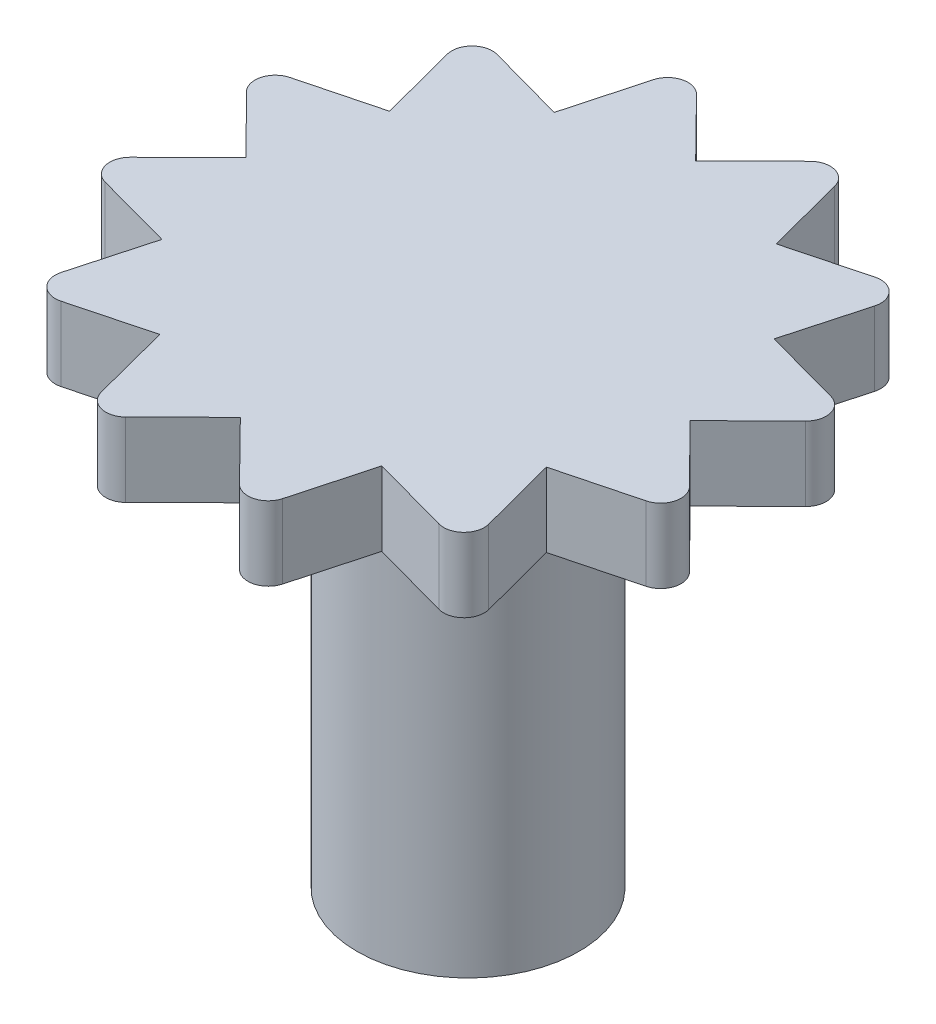
from build123d import *

# Parameters (mm, degrees)
BOSS_EXTRUDE1_DEPTH = 1
SKETCH2_R           = 1.5
BOSS_EXTRUDE2_DEPTH = 6


with BuildPart() as part:
    # Sketch1 → Boss-Extrude1 (new body)
    with BuildSketch(Plane(origin=(0, 0, 0), x_dir=(1, 0, 0), z_dir=(0, 1, 0))):
        with BuildLine():
            Line((0.038153439, 3.037815087), (0.816252158, 3.809013473))
            ThreePointArc((0.816252158, 3.809013473), (1.082123997, 3.875868882), (1.274025664, 3.680085251))
            Line((1.274025664, 3.680085251), (1.551949391, 2.611748318))
            Line((1.551949391, 2.611748318), (2.611401842, 2.890576352))
            ThreePointArc((2.611401842, 2.890576352), (2.875081312, 2.815538915), (2.943381216, 2.550034483))
            Line((2.943381216, 2.550034483), (2.649901757, 1.485865696))
            Line((2.649901757, 1.485865696), (3.70682851, 1.197611631))
            ThreePointArc((3.70682851, 1.197611631), (3.897662912, 1.00078757), (3.824060148, 0.736704035))
            Line((3.824060148, 0.736704035), (3.037815087, -0.038153439))
            Line((3.037815087, -0.038153439), (3.809013473, -0.816252158))
            ThreePointArc((3.809013473, -0.816252158), (3.875868882, -1.082123997), (3.680085251, -1.274025664))
            Line((3.680085251, -1.274025664), (2.611748318, -1.551949391))
            Line((2.611748318, -1.551949391), (2.890576352, -2.611401842))
            ThreePointArc((2.890576352, -2.611401842), (2.815538915, -2.875081312), (2.550034483, -2.943381216))
            Line((2.550034483, -2.943381216), (1.485865696, -2.649901757))
            Line((1.485865696, -2.649901757), (1.197611631, -3.70682851))
            ThreePointArc((1.197611631, -3.70682851), (1.00078757, -3.897662912), (0.736704035, -3.824060148))
            Line((0.736704035, -3.824060148), (-0.038153439, -3.037815087))
            Line((-0.038153439, -3.037815087), (-0.816252158, -3.809013473))
            ThreePointArc((-0.816252158, -3.809013473), (-1.082123997, -3.875868882), (-1.274025664, -3.680085251))
            Line((-1.274025664, -3.680085251), (-1.551949391, -2.611748318))
            Line((-1.551949391, -2.611748318), (-2.611401842, -2.890576352))
            ThreePointArc((-2.611401842, -2.890576352), (-2.875081312, -2.815538915), (-2.943381216, -2.550034483))
            Line((-2.943381216, -2.550034483), (-2.649901757, -1.485865696))
            Line((-2.649901757, -1.485865696), (-3.70682851, -1.197611631))
            ThreePointArc((-3.70682851, -1.197611631), (-3.897662912, -1.00078757), (-3.824060148, -0.736704035))
            Line((-3.824060148, -0.736704035), (-3.037815087, 0.038153439))
            Line((-3.037815087, 0.038153439), (-3.809013473, 0.816252158))
            ThreePointArc((-3.809013473, 0.816252158), (-3.875868882, 1.082123997), (-3.680085251, 1.274025664))
            Line((-3.680085251, 1.274025664), (-2.611748318, 1.551949391))
            Line((-2.611748318, 1.551949391), (-2.890576352, 2.611401842))
            ThreePointArc((-2.890576352, 2.611401842), (-2.815538915, 2.875081312), (-2.550034483, 2.943381216))
            Line((-2.550034483, 2.943381216), (-1.485865696, 2.649901757))
            Line((-1.485865696, 2.649901757), (-1.197611631, 3.70682851))
            ThreePointArc((-1.197611631, 3.70682851), (-1.00078757, 3.897662912), (-0.736704035, 3.824060148))
            Line((-0.736704035, 3.824060148), (0.038153439, 3.037815087))
        make_face()
    extrude(amount=BOSS_EXTRUDE1_DEPTH)

    # Sketch2 → Boss-Extrude2 (add)
    with BuildSketch(Plane.XZ):
        Circle(SKETCH2_R)
    extrude(amount=BOSS_EXTRUDE2_DEPTH)


solid = part.part
